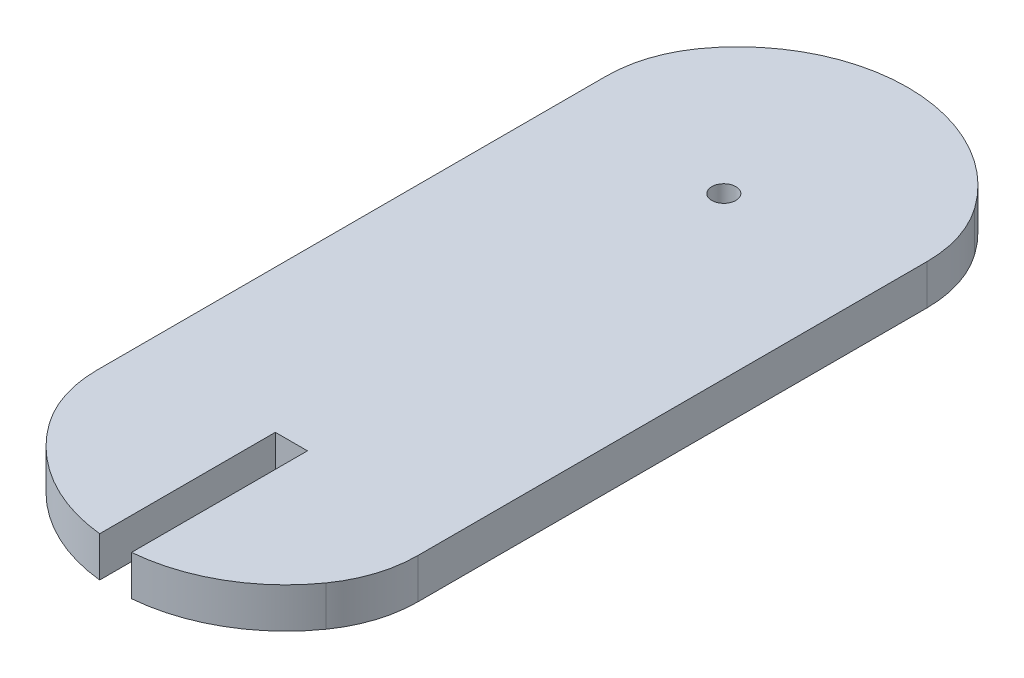
from build123d import *

# Parameters (mm, degrees)
SKETCH2_W           = 40
SKETCH2_H           = 70
BOSS_EXTRUDE1_DEPTH = 5
FILLET1_R           = 15
CUT_EXTRUDE1_DEPTH  = 6
SKETCH4_R           = 1.5
CUT_EXTRUDE2_DEPTH  = 6


with BuildPart() as part:
    # Sketch2 → Boss-Extrude1 (new body)
    with BuildSketch(Plane(origin=(0, 0, 0), x_dir=(1, 0, 0), z_dir=(0, 1, 0))):
        with BuildLine():
            Line((-20, -35), (20, -35))
            ThreePointArc((20, -35), (0, -49.312603136), (-20, -35))
        make_face()
        Rectangle(SKETCH2_W, SKETCH2_H)
        with BuildLine():
            ThreePointArc((-20, 35), (0, 49.305454963), (20, 35))
            Line((20, 35), (-20, 35))
        make_face()
    extrude(amount=BOSS_EXTRUDE1_DEPTH)

    # Fillet1
    fillet1_edges = [part.edges().sort_by_distance(p)[0] for p in [
        (-20, 2.5, 35),
        (-20, 2.5, -35),
        (20, 2.5, -35),
        (20, 2.5, 35),
    ]]
    fillet(fillet1_edges, radius=FILLET1_R)

    # Sketch3 → Cut-Extrude1 (cut, through all)
    with BuildSketch(Plane.XZ):
        Polygon((0, 49.312603136), (1.823748233, 49.312603136), (1.823748233, 27.312603136), (-2.176251767, 27.312603136), (-2.176251767, 49.312603136), align=None)
    extrude(amount=-CUT_EXTRUDE1_DEPTH, mode=Mode.SUBTRACT)

    # Sketch4 → Cut-Extrude2 (cut, through all)
    with BuildSketch(Plane.XZ):
        with Locations((0, -26.387396864)):
            Circle(SKETCH4_R)
    extrude(amount=-CUT_EXTRUDE2_DEPTH, mode=Mode.SUBTRACT)


solid = part.part
